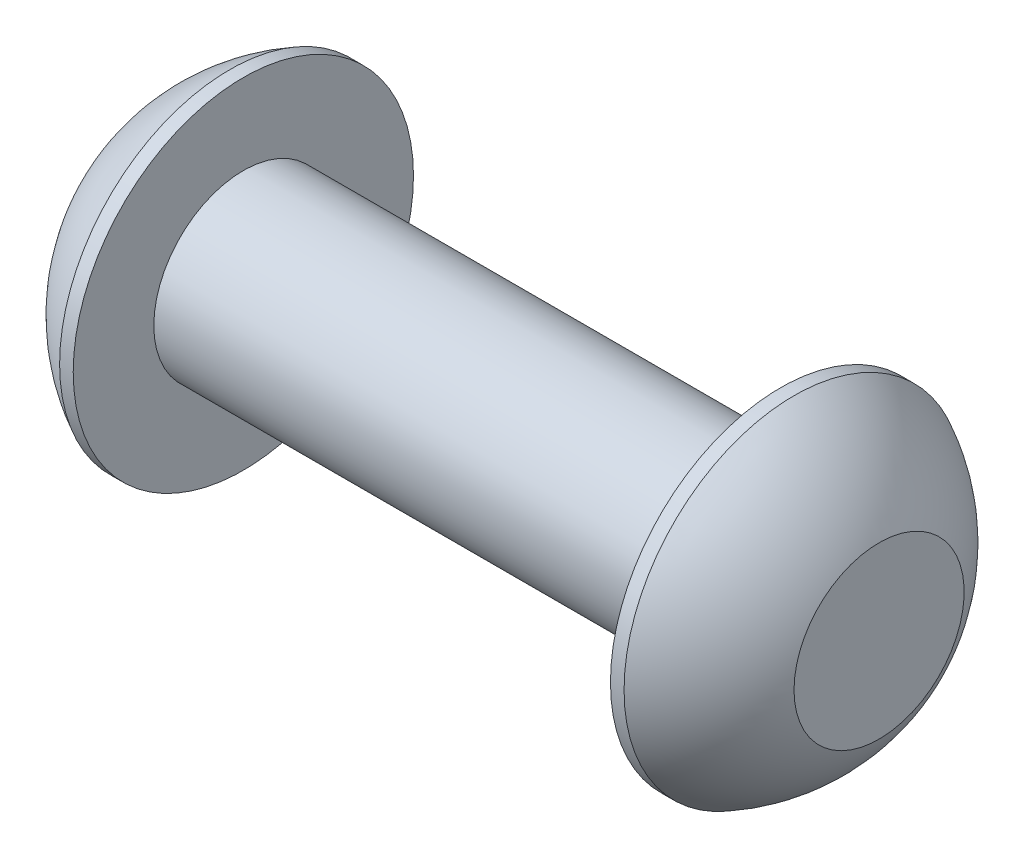
from build123d import *


with BuildPart() as part:
    # Sketch2 → Revolve1 (revolve)
    with BuildSketch(Plane.XY):
        with BuildLine():
            ThreePointArc((0, 2.375), (0.992680215, 3.754414901), (2.37, 4.75))
            Line((2.37, 4.75), (2.75, 4.75))
            Line((2.75, 4.75), (2.75, 2.5))
            Line((2.75, 2.5), (17.75, 2.5))
            Line((17.75, 2.5), (17.75, 4.75))
            Line((17.75, 4.75), (18.13, 4.75))
            ThreePointArc((18.13, 4.75), (19.507319785, 3.754414901), (20.5, 2.375))
            Line((20.5, 2.375), (20.5, 0))
            Line((20.5, 0), (0, 0))
            Line((0, 0), (0, 2.375))
        make_face()
    revolve(axis=Axis((-1.178114582, 0, 0), (1, 0, 0)))


solid = part.part
